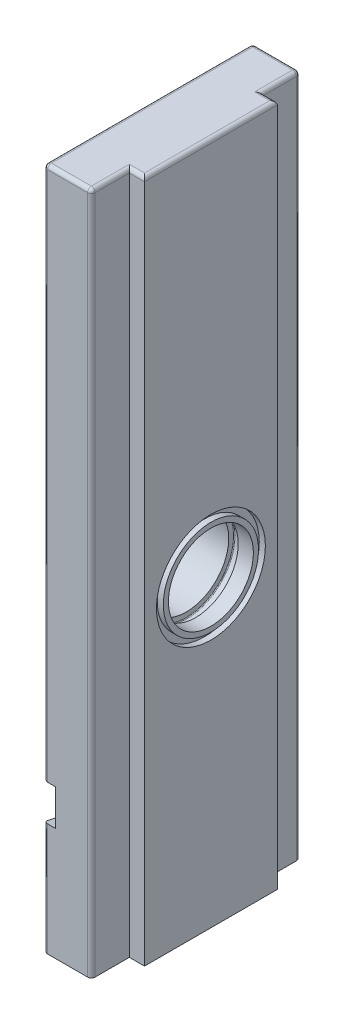
from build123d import *

# Parameters (mm, degrees)
BOSS_EXTRUDE1_DEPTH   = 180
SKETCH3_R             = 11.2
CUT_EXTRUDE1_DEPTH    = 17.5
SKETCH11_W            = 1.6
SKETCH11_H            = 1.8
LPATTERN1_COUNT       = 2
LPATTERN1_PITCH       = 60
M6_TAPPED_HOLE1_D     = 5
M6_TAPPED_HOLE1_DEPTH = 27
M6_TAPPED_HOLE1_TIP   = 1.502151548
CUT_EXTRUDE2_DEPTH    = 3
FILLET1_R             = 1
SKETCH16_R            = 16.086182712
BOSS_EXTRUDE2_DEPTH   = 16.5


with BuildPart() as part:
    # Sketch1 → Boss-Extrude1 (new body)
    with BuildSketch(Plane(origin=(0, 0, 0), x_dir=(1, 0, 0), z_dir=(0, 1, 0))):
        Polygon((0, 0), (0, 55), (12.5, 55), (12.5, 45), (16.5, 45), (16.5, 10), (12.5, 10), (12.5, 0), align=None)
    extrude(amount=BOSS_EXTRUDE1_DEPTH)

    # Sketch3 → Cut-Extrude1 (cut, through all)
    with BuildSketch(Plane(origin=(16.5, 0, 0), x_dir=(0, 0, -1), z_dir=(1, 0, 0))):
        with Locations((27.5, 80)):
            Circle(SKETCH3_R)
    cut_extrude1 = extrude(amount=-CUT_EXTRUDE1_DEPTH, mode=Mode.SUBTRACT)

    # Sketch11 → Cut-Revolve1 (revolve, cut)
    with BuildSketch(Plane.XY.offset(-27.5)):
        with BuildLine():
            Line((10, 69.15), (12.5, 69.15))
            Line((12.5, 69.15), (12.5, 67.55))
            ThreePointArc((12.5, 67.55), (12.441421356, 67.408578644), (12.3, 67.35))
            Line((12.3, 67.35), (10.2, 67.35))
            ThreePointArc((10.2, 67.35), (10.058578644, 67.408578644), (10, 67.55))
            Line((10, 67.55), (10, 69.15))
        make_face()
        with Locations((15.7, 66.55)):
            Rectangle(SKETCH11_W, SKETCH11_H)
    cut_revolve1 = revolve(axis=Axis((16.5, 80, -27.5), (-1, 0, 0)), mode=Mode.SUBTRACT)

    # LPattern1: Cut-Extrude1, Cut-Revolve1 ×2
    with Locations(*[(0, i * LPATTERN1_PITCH, 0) for i in range(1, LPATTERN1_COUNT)]):
        add(cut_extrude1, mode=Mode.SUBTRACT)
        add(cut_revolve1, mode=Mode.SUBTRACT)

    # M6 Tapped Hole1
    with Locations(Plane.XZ):
        with Locations((6.5, -12.5), (6.5, -42.5)):
            Hole(M6_TAPPED_HOLE1_D / 2, depth=M6_TAPPED_HOLE1_DEPTH)
            with Locations((0, 0, -(M6_TAPPED_HOLE1_DEPTH + M6_TAPPED_HOLE1_TIP / 2))):  # 118° drill point
                Cone(0, M6_TAPPED_HOLE1_D / 2, M6_TAPPED_HOLE1_TIP, mode=Mode.SUBTRACT)

    # Sketch15 → Cut-Extrude2 (cut)
    with BuildSketch(Plane.ZY):
        Polygon((-55, 144.75), (-45.5, 146.75), (-45.5, 133.25), (-55, 135.25), align=None)
        Polygon((-55, 78.4), (-45.5, 80.4), (-45.5, 66.9), (-55, 68.9), align=None)
        Polygon((0, 39.2), (-9.5, 41.2), (-9.5, 27.7), (0, 29.7), align=None)
    extrude(amount=-CUT_EXTRUDE2_DEPTH, mode=Mode.SUBTRACT)

    # Fillet1
    fillet1_edges = [part.edges().sort_by_distance(p)[0] for p in [
        (14.5, 180, -10),
        (16.5, 180, -27.5),
        (0, 109.6, 0),
        (0, 162.375, -55),
        (12.5, 90, -55),
        (12.5, 90, 0),
        (14.5, 180, -45),
        (12.5, 180, -50),
        (6.25, 180, -55),
        (0, 180, -27.5),
        (6.25, 180, 0),
        (12.5, 180, -5),
        (0, 106.825, -55),
        (0, 34.45, -55),
        (0, 14.85, 0),
    ]]
    fillet(fillet1_edges, radius=FILLET1_R)

    # Sketch16 → Boss-Extrude2 (add)
    with BuildSketch(Plane(origin=(16.5, 0, 0), x_dir=(0, 0, -1), z_dir=(1, 0, 0))):
        with Locations((27.5, 140)):
            Circle(SKETCH16_R)
    extrude(amount=-BOSS_EXTRUDE2_DEPTH)


solid = part.part
